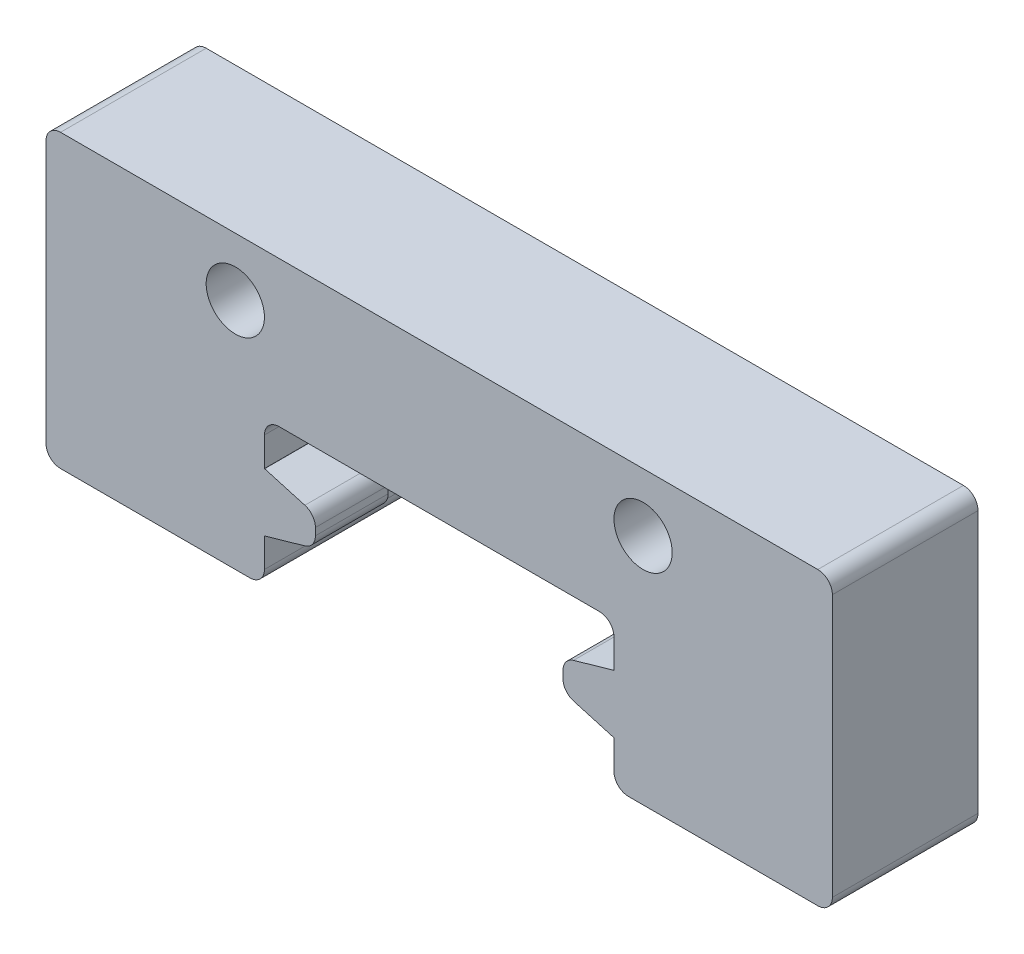
from build123d import *

# Parameters (mm, degrees)
BOSS_EXTRUDE1_DEPTH   = 5
CHAMFER1_SIZE         = 0.5
CHAMFER1_SIZE2        = 1.743707222
CHAMFER1_PART_2_SIZE  = 0.5
CHAMFER1_PART_2_SIZE2 = 1.743707222
FILLET1_R             = 0.5
SKETCH2_R             = 1
CUT_EXTRUDE1_DEPTH    = 5
FILLET2_R             = 0.5
SKETCH4_W             = 6.75
SKETCH4_H             = 2.5
CUT_EXTRUDE2_DEPTH    = 2.5


with BuildPart() as part:
    # Sketch1 → Boss-Extrude1 (new body)
    with BuildSketch(Plane.XY):
        Polygon((-6, -1.5), (-6, 0), (6, 0), (6, -1.5), (4.25, -1.5), (4.25, -3.5), (6, -3.5), (6, -5), (13.5, -5), (13.5, 5), (-13.5, 5), (-13.5, -5), (-6, -5), (-6, -3.5), (-4.25, -3.5), (-4.25, -1.5), align=None)
    extrude(amount=BOSS_EXTRUDE1_DEPTH)

    # Chamfer1
    chamfer1_edges = [part.edges().sort_by_distance(p)[0] for p in [
        (4.25, -3.5, 2.5),
        (4.25, -1.5, 2.5),
    ]]
    chamfer1_side = [part.faces().sort_by_distance(p)[0] for p in [
        (4.25, -2.5, 2.5),
    ]]
    chamfer(chamfer1_edges, length=CHAMFER1_SIZE, length2=CHAMFER1_SIZE2, reference=chamfer1_side[0])

    # Chamfer1 part 2
    chamfer1_part_2_edges = [part.edges().sort_by_distance(p)[0] for p in [
        (-4.25, -1.5, 2.5),
        (-4.25, -3.5, 2.5),
    ]]
    chamfer1_part_2_side = [part.faces().sort_by_distance(p)[0] for p in [
        (-4.25, -2.5, 2.5),
    ]]
    chamfer(chamfer1_part_2_edges, length=CHAMFER1_PART_2_SIZE, length2=CHAMFER1_PART_2_SIZE2, reference=chamfer1_part_2_side[0])

    # Fillet1
    fillet1_edges = [part.edges().sort_by_distance(p)[0] for p in [
        (4.25, -2, 2.5),
        (4.25, -3, 2.5),
        (-4.25, -2, 2.5),
        (-4.25, -3, 2.5),
    ]]
    fillet(fillet1_edges, radius=FILLET1_R)

    # Sketch2 → Cut-Extrude1 (cut)
    with BuildSketch(Plane.XY.offset(5)):
        with Locations((-7, 3)):
            Circle(SKETCH2_R)
        with Locations((7, 3)):
            Circle(SKETCH2_R)
    extrude(amount=-CUT_EXTRUDE1_DEPTH, mode=Mode.SUBTRACT)

    # Fillet2
    fillet2_edges = [part.edges().sort_by_distance(p)[0] for p in [
        (6, -5, 2.5),
        (6, 0, 2.5),
        (-6, 0, 2.5),
        (-6, -5, 2.5),
        (-13.5, -5, 2.5),
        (-13.5, 5, 2.5),
        (13.5, 5, 2.5),
        (13.5, -5, 2.5),
    ]]
    fillet(fillet2_edges, radius=FILLET2_R)

    # Sketch4 → Cut-Extrude2 (cut)
    with BuildSketch(Plane(origin=(0, 0, 0), x_dir=(-1, 0, 0), z_dir=(0, 0, -1))):
        with Locations((-7.625, -2.5)):
            Rectangle(SKETCH4_W, SKETCH4_H)
        with Locations((7.625, -2.5)):
            Rectangle(SKETCH4_W, SKETCH4_H)
    extrude(amount=-CUT_EXTRUDE2_DEPTH, mode=Mode.SUBTRACT)


solid = part.part
